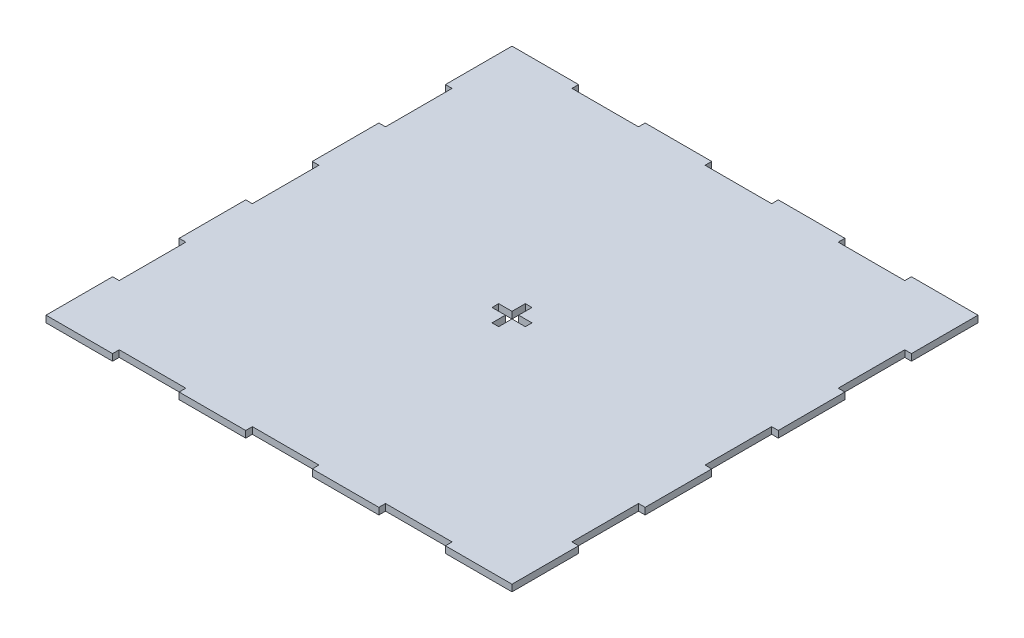
from build123d import *

# Parameters (mm, degrees)
SKETCH1_W           = 420
SKETCH1_H           = 420
BOSS_EXTRUDE1_DEPTH = 6
SKETCH3_W           = 6
SKETCH3_H           = 60
SKETCH3_W_2         = 60
SKETCH3_H_2         = 6
CUT_EXTRUDE2_DEPTH  = 7
CUT_EXTRUDE3_DEPTH  = 7


with BuildPart() as part:
    # Sketch1 → Boss-Extrude1 (new body)
    with BuildSketch(Plane(origin=(0, 0, 0), x_dir=(1, 0, 0), z_dir=(0, 1, 0))):
        Rectangle(SKETCH1_W, SKETCH1_H)
    extrude(amount=BOSS_EXTRUDE1_DEPTH)

    # Sketch3 → Cut-Extrude2 (cut, through all)
    with BuildSketch(Plane(origin=(0, 6, 0), x_dir=(1, 0, 0), z_dir=(0, 1, 0))):
        with Locations((-207, 120)):
            Rectangle(SKETCH3_W, SKETCH3_H)
        with Locations((-207, 0)):
            Rectangle(SKETCH3_W, SKETCH3_H)
        with Locations((-207, -120)):
            Rectangle(SKETCH3_W, SKETCH3_H)
        with Locations((120, 207)):
            Rectangle(SKETCH3_W_2, SKETCH3_H_2)
        with Locations((0, 207)):
            Rectangle(SKETCH3_W_2, SKETCH3_H_2)
        with Locations((-120, 207)):
            Rectangle(SKETCH3_W_2, SKETCH3_H_2)
        with Locations((207, -120)):
            Rectangle(SKETCH3_W, SKETCH3_H)
        with Locations((207, 0)):
            Rectangle(SKETCH3_W, SKETCH3_H)
        with Locations((207, 120)):
            Rectangle(SKETCH3_W, SKETCH3_H)
        with Locations((-120, -207)):
            Rectangle(SKETCH3_W_2, SKETCH3_H_2)
        with Locations((0, -207)):
            Rectangle(SKETCH3_W_2, SKETCH3_H_2)
        with Locations((120, -207)):
            Rectangle(SKETCH3_W_2, SKETCH3_H_2)
    extrude(amount=-CUT_EXTRUDE2_DEPTH, mode=Mode.SUBTRACT)

    # Sketch5 → Cut-Extrude3 (cut, through all)
    with BuildSketch(Plane(origin=(0, 6, 0), x_dir=(1, 0, 0), z_dir=(0, 1, 0))):
        Polygon((3, 3), (15, 3), (15, -3), (3, -3), (3, -15), (-3, -15), (-3, -3), (-15, -3), (-15, 3), (-3, 3), (-3, 15), (3, 15), align=None)
    extrude(amount=-CUT_EXTRUDE3_DEPTH, mode=Mode.SUBTRACT)


solid = part.part
